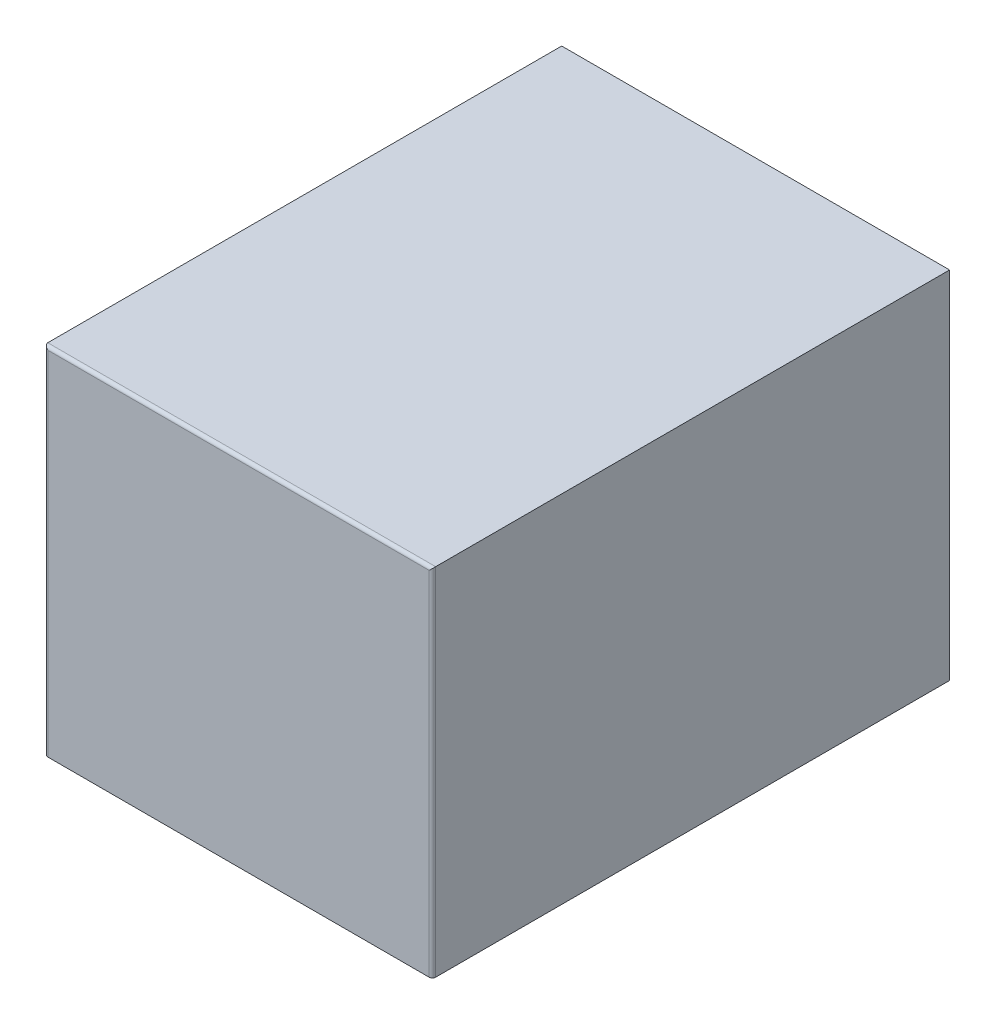
from build123d import *

# Parameters (mm, degrees)
SKETCH1_W           = 12
SKETCH1_H           = 16
BOSS_EXTRUDE1_DEPTH = 11
CUT_EXTRUDE1_DEPTH  = 11
FILLET1_R           = 0.1
SKETCH5_W           = 6.545638519
SKETCH5_H           = 3.78409842
BOSS_EXTRUDE2_DEPTH = 10


with BuildPart() as part:
    # Sketch1 → Boss-Extrude1 (new body)
    with BuildSketch(Plane(origin=(0, 0, 0), x_dir=(1, 0, 0), z_dir=(0, 1, 0))):
        Rectangle(SKETCH1_W, SKETCH1_H)
    extrude(amount=BOSS_EXTRUDE1_DEPTH)

    # Sketch4 → Cut-Extrude1 (cut)
    with BuildSketch(Plane(origin=(0, 0, -8), x_dir=(-1, 0, 0), z_dir=(0, 0, -1))):
        Polygon((-4.942176734, 1.304641084), (5.205759493, 1.304641084), (5.205759493, 7.432940234), (3.404610639, 9.849115526), (-3.0092365, 9.849115526), (-4.942176734, 7.432940234), align=None)
    extrude(amount=-CUT_EXTRUDE1_DEPTH, mode=Mode.SUBTRACT)

    # Fillet1
    fillet1_edges = [part.edges().sort_by_distance(p)[0] for p in [
        (0, 11, 8),
        (6, 5.5, 8),
        (-6, 5.5, 8),
    ]]
    fillet(fillet1_edges, radius=FILLET1_R)

    # Sketch5 → Boss-Extrude2 (add)
    with BuildSketch(Plane(origin=(0, 0, 3), x_dir=(-1, 0, 0), z_dir=(0, 0, -1))):
        with Locations((0.13179138, 5.389997139)):
            Rectangle(SKETCH5_W, SKETCH5_H)
    extrude(amount=BOSS_EXTRUDE2_DEPTH)


solid = part.part
